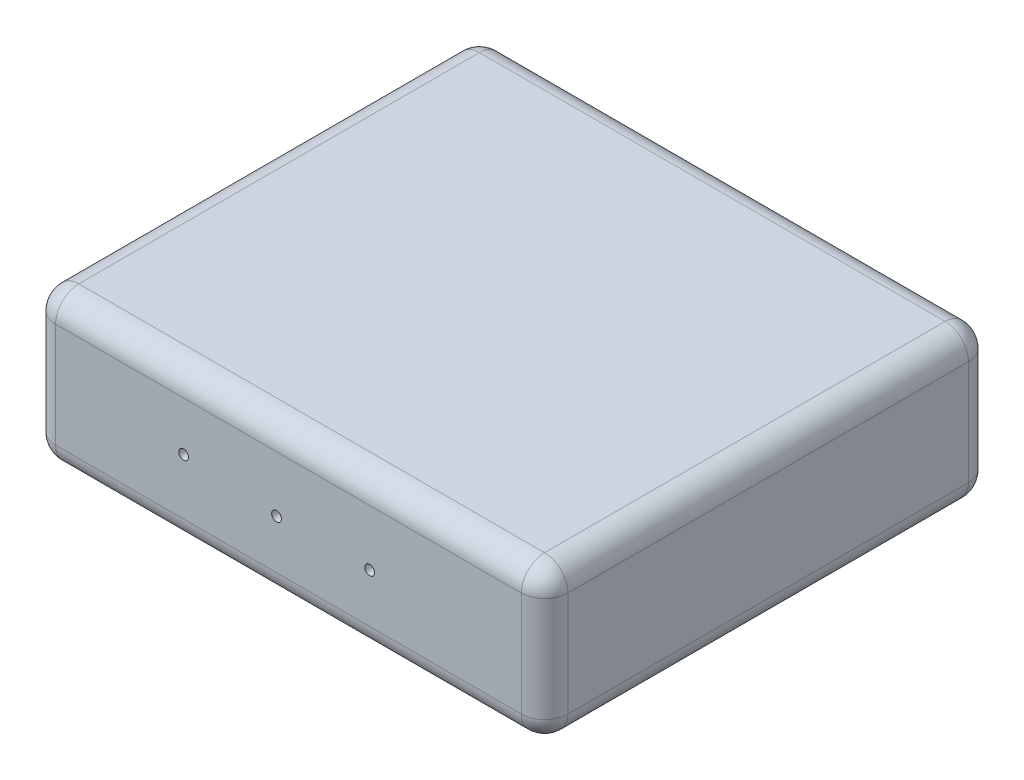
from build123d import *

# Parameters (mm, degrees)
SKETCH1_W                      = 220
SKETCH1_H                      = 192
BOSS_EXTRUDE1_DEPTH            = 65
FILLET1_R                      = 10
F_4_2_4_2_DIAMETER_HOLE1_D     = 4.2
F_4_2_4_2_DIAMETER_HOLE1_DEPTH = 10
F_4_2_4_2_DIAMETER_HOLE1_TIP   = 1.2618073
F_4_2_4_2_DIAMETER_HOLE2_D     = 4.2
F_4_2_4_2_DIAMETER_HOLE2_DEPTH = 10
F_4_2_4_2_DIAMETER_HOLE2_TIP   = 1.2618073


with BuildPart() as part:
    # Sketch1 → Boss-Extrude1 (new body)
    with BuildSketch(Plane(origin=(0, 0, 0), x_dir=(1, 0, 0), z_dir=(0, 1, 0))):
        Rectangle(SKETCH1_W, SKETCH1_H)
    extrude(amount=BOSS_EXTRUDE1_DEPTH)

    # Fillet1
    fillet1_edges = [part.edges().sort_by_distance(p)[0] for p in [
        (110, 65, 0),
        (0, 65, -96),
        (-110, 65, 0),
        (0, 0, -96),
        (110, 0, 0),
        (0, 0, 96),
        (-110, 0, 0),
        (0, 65, 96),
        (-110, 32.5, -96),
        (110, 32.5, -96),
        (110, 32.5, 96),
        (-110, 32.5, 96),
    ]]
    fillet(fillet1_edges, radius=FILLET1_R)

    # Ø4.2 (4.2) Diameter Hole1
    with Locations(Plane.XY.offset(96)):
        with Locations((-45, 34), (-5.112027604, 31.00840207), (34.887971518, 31.000023466)):
            Hole(F_4_2_4_2_DIAMETER_HOLE1_D / 2, depth=F_4_2_4_2_DIAMETER_HOLE1_DEPTH)
            with Locations((0, 0, -(F_4_2_4_2_DIAMETER_HOLE1_DEPTH + F_4_2_4_2_DIAMETER_HOLE1_TIP / 2))):  # 118° drill point
                Cone(0, F_4_2_4_2_DIAMETER_HOLE1_D / 2, F_4_2_4_2_DIAMETER_HOLE1_TIP, mode=Mode.SUBTRACT)

    # Ø4.2 (4.2) Diameter Hole2
    with Locations(Plane(origin=(0, 0, -96), x_dir=(-1, 0, 0), z_dir=(0, 0, -1))):
        with Locations((-45, 34), (-5.112027604, 31.00840207), (34.887971518, 31.000023466)):
            Hole(F_4_2_4_2_DIAMETER_HOLE2_D / 2, depth=F_4_2_4_2_DIAMETER_HOLE2_DEPTH)
            with Locations((0, 0, -(F_4_2_4_2_DIAMETER_HOLE2_DEPTH + F_4_2_4_2_DIAMETER_HOLE2_TIP / 2))):  # 118° drill point
                Cone(0, F_4_2_4_2_DIAMETER_HOLE2_D / 2, F_4_2_4_2_DIAMETER_HOLE2_TIP, mode=Mode.SUBTRACT)


solid = part.part
